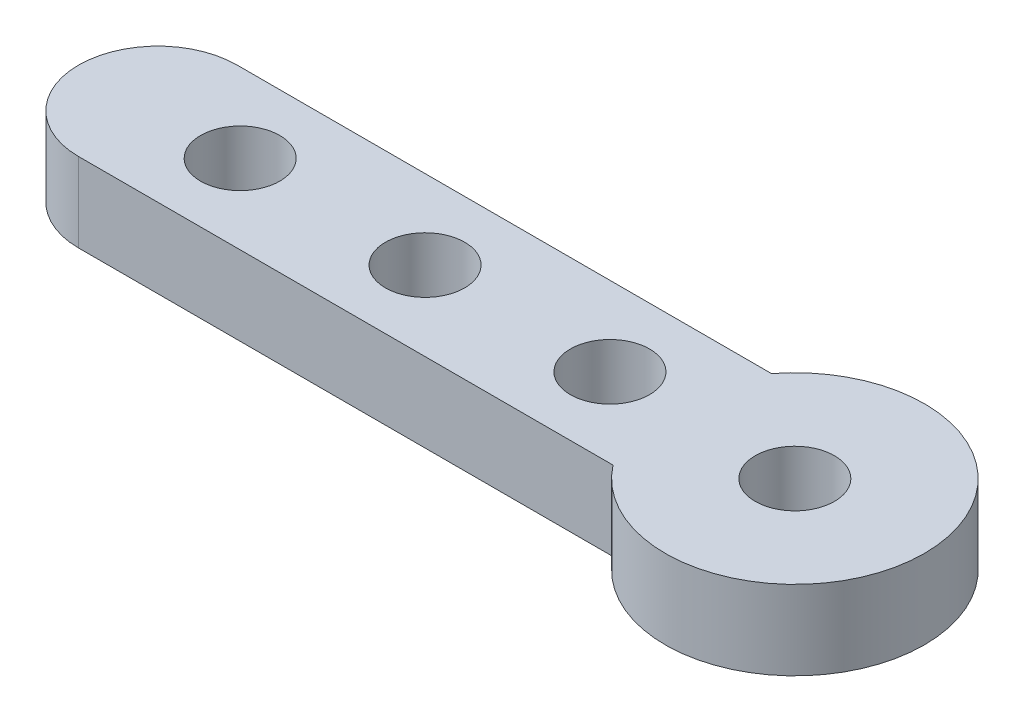
from build123d import *

# Parameters (mm, degrees)
SKETCH2_R           = 1.5
BOSS_EXTRUDE1_DEPTH = 3


with BuildPart() as part:
    # Sketch2 → Boss-Extrude1 (new body)
    with BuildSketch(Plane(origin=(0, 0, 0), x_dir=(1, 0, 0), z_dir=(0, 1, 0))):
        with BuildLine():
            Line((4.883857953, 0), (25.116142047, 0))
            ThreePointArc((25.116142047, 0), (33.907581135, 3), (25.116142047, 6))
            Line((25.116142047, 6), (4.883857953, 6))
            ThreePointArc((4.883857953, 6), (1.883857953, 3), (4.883857953, 0))
        make_face()
        with Locations((15, 3)):
            Circle(SKETCH2_R, mode=Mode.SUBTRACT)
        with Locations((8, 3)):
            Circle(SKETCH2_R, mode=Mode.SUBTRACT)
        with Locations((22, 3)):
            Circle(SKETCH2_R, mode=Mode.SUBTRACT)
        with Locations((29, 3)):
            Circle(SKETCH2_R, mode=Mode.SUBTRACT)
    extrude(amount=BOSS_EXTRUDE1_DEPTH)


solid = part.part
